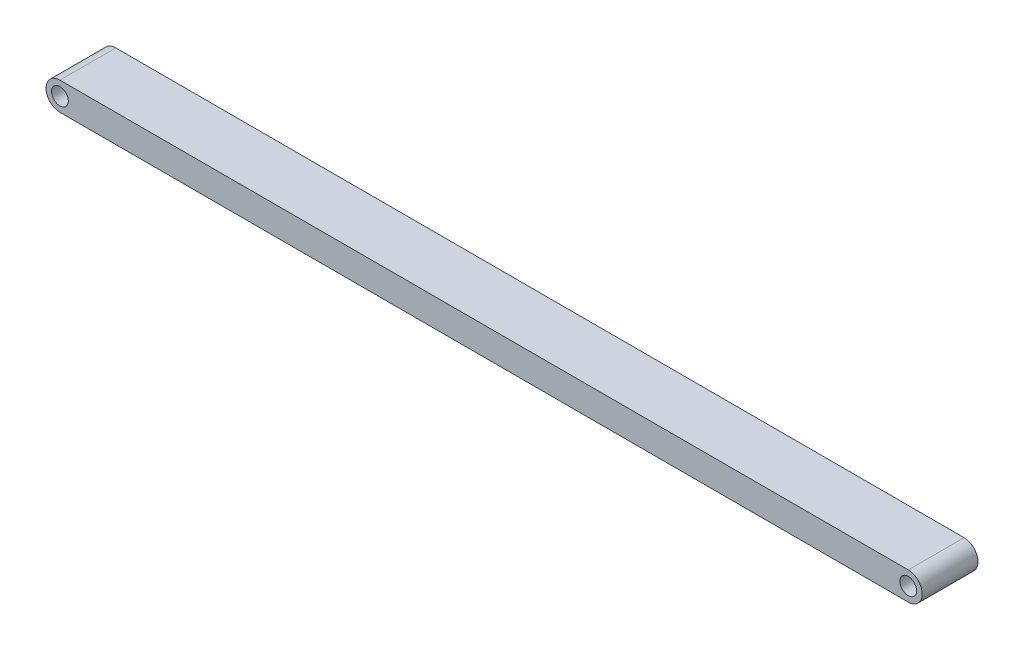
from build123d import *

# Parameters (mm, degrees)
ESQUISSE1_R        = 1.5
BOSS_EXTRU_1_DEPTH = 10


with BuildPart() as part:
    # Esquisse1 → Boss.-Extru.1 (new body)
    with BuildSketch(Plane.XY):
        with BuildLine():
            Line((0, 0), (152, 0))
            ThreePointArc((152, 0), (154.5, 2.5), (152, 5))
            Line((152, 5), (0, 5))
            ThreePointArc((0, 5), (-2.5, 2.5), (0, 0))
        make_face()
        with Locations((0, 2.5)):
            Circle(ESQUISSE1_R, mode=Mode.SUBTRACT)
        with Locations((152, 2.5)):
            Circle(ESQUISSE1_R, mode=Mode.SUBTRACT)
    extrude(amount=BOSS_EXTRU_1_DEPTH)


solid = part.part
